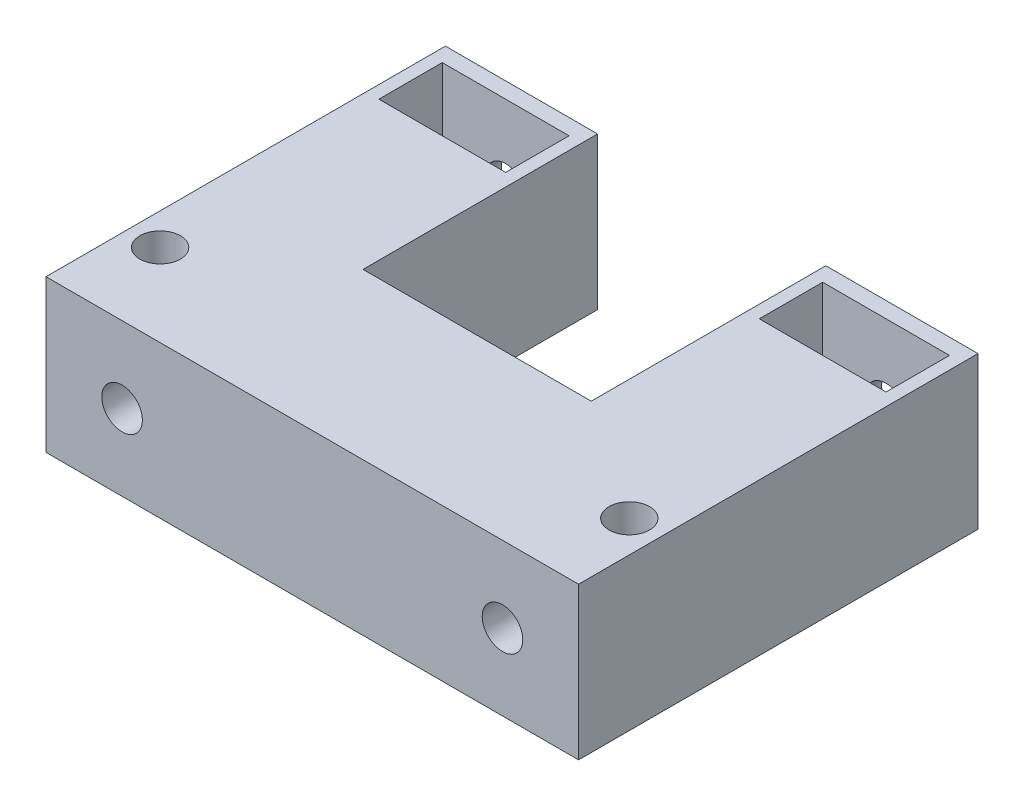
from build123d import *

# Parameters (mm, degrees)
SALIENTE_EXTRUIR1_DEPTH   = 5
SALIENTE_EXTRUIR1_2_DEPTH = 5
CROQUIS3_W                = 12
CROQUIS3_H                = 12
SALIENTE_EXTRUIR2_DEPTH   = 1.25
CROQUIS4_W                = 12
CROQUIS4_H                = 12
SALIENTE_EXTRUIR3_DEPTH   = 1.25
CROQUIS5_R                = 1.6
CORTAR_EXTRUIR1_DEPTH     = 1.25
CROQUIS9_R                = 1.6
CORTAR_EXTRUIR2_DEPTH     = 1.25
CROQUIS11_W               = 12
CROQUIS11_H               = 12
CROQUIS11_R               = 1.6
SALIENTE_EXTRUIR4_DEPTH   = 24
CROQUIS13_W               = 13
CROQUIS13_H               = 12
SALIENTE_EXTRUIR6_DEPTH   = 30
CROQUIS14_W               = 12
CROQUIS14_H               = 12
SALIENTE_EXTRUIR8_DEPTH   = 18.5
CROQUIS15_W               = 10
CROQUIS15_H               = 5
CORTAR_EXTRUIR3_DEPTH     = 12
CROQUIS16_R               = 1.6
CORTAR_EXTRUIR5_DEPTH     = 32
CROQUIS17_R               = 1.6
CORTAR_EXTRUIR6_DEPTH     = 12


with BuildPart() as part:
    # Croquis2 → Saliente-Extruir1 (new body)
    with BuildSketch(Plane.XY):
        Polygon((-5, -6), (-5, -5), (-5, 5), (-5, 6), (-6, 6), (-6, 5), (-6, -6), align=None)
    extrude(amount=SALIENTE_EXTRUIR1_DEPTH)



with BuildPart() as body_2:
    # Croquis2 → Saliente-Extruir1 2 (new body)
    with BuildSketch(Plane.XY):
        Polygon((5, 5), (5, -5), (5, -6), (6, -6), (6, 6), (5, 6), align=None)
    extrude(amount=SALIENTE_EXTRUIR1_2_DEPTH)


with BuildPart() as part_1:
    add(part.part)

    add(body_2.part)  # Saliente-Extruir2 merges body 2
    # Croquis3 → Saliente-Extruir2 (add)
    with BuildSketch(Plane(origin=(0, 0, 0), x_dir=(-1, 0, 0), z_dir=(0, 0, -1))):
        Rectangle(CROQUIS3_W, CROQUIS3_H)
    extrude(amount=SALIENTE_EXTRUIR2_DEPTH)

    # Croquis4 → Saliente-Extruir3 (add)
    with BuildSketch(Plane.XY.offset(5)):
        Rectangle(CROQUIS4_W, CROQUIS4_H)
    extrude(amount=SALIENTE_EXTRUIR3_DEPTH)

    # Croquis5 → Cortar-Extruir1 (cut)
    with BuildSketch(Plane.XY.offset(6.25)):
        Circle(CROQUIS5_R)
    extrude(amount=-CORTAR_EXTRUIR1_DEPTH, mode=Mode.SUBTRACT)

    # Croquis9 → Cortar-Extruir2 (cut)
    with BuildSketch(Plane.XY):
        Circle(CROQUIS9_R)
    extrude(amount=-CORTAR_EXTRUIR2_DEPTH, mode=Mode.SUBTRACT)

    # Croquis11 → Saliente-Extruir4 (add)
    with BuildSketch(Plane.XY.offset(6.25)):
        Rectangle(CROQUIS11_W, CROQUIS11_H)
        Circle(CROQUIS11_R, mode=Mode.SUBTRACT)
    extrude(amount=SALIENTE_EXTRUIR4_DEPTH)

    # Croquis13 → Saliente-Extruir6 (add)
    with BuildSketch(Plane(origin=(6, 0, 0), x_dir=(0, 0, -1), z_dir=(1, 0, 0))):
        with Locations((-23.75, 0)):
            Rectangle(CROQUIS13_W, CROQUIS13_H)
    extrude(amount=SALIENTE_EXTRUIR6_DEPTH)

    # Croquis14 → Saliente-Extruir8 (add)
    with BuildSketch(Plane(origin=(0, 0, 17.25), x_dir=(-1, 0, 0), z_dir=(0, 0, -1))):
        with Locations((-30, 0)):
            Rectangle(CROQUIS14_W, CROQUIS14_H)
    extrude(amount=SALIENTE_EXTRUIR8_DEPTH)

    # Croquis15 → Cortar-Extruir3 (cut)
    with BuildSketch(Plane(origin=(0, 6, 0), x_dir=(1, 0, 0), z_dir=(0, 1, 0))):
        with Locations((30, -2.5)):
            Rectangle(CROQUIS15_W, CROQUIS15_H)
    extrude(amount=-CORTAR_EXTRUIR3_DEPTH, mode=Mode.SUBTRACT)

    # Croquis16 → Cortar-Extruir5 (cut)
    with BuildSketch(Plane.XY.offset(30.25)):
        Circle(CROQUIS16_R)
        with Locations((30, 0)):
            Circle(CROQUIS16_R)
    extrude(amount=-CORTAR_EXTRUIR5_DEPTH, mode=Mode.SUBTRACT)

    # Croquis17 → Cortar-Extruir6 (cut)
    with BuildSketch(Plane(origin=(0, 6, 0), x_dir=(1, 0, 0), z_dir=(0, 1, 0))):
        with Locations((-3.5, -23.75)):
            Circle(CROQUIS17_R)
        with Locations((33.5, -23.75)):
            Circle(CROQUIS17_R)
    extrude(amount=-CORTAR_EXTRUIR6_DEPTH, mode=Mode.SUBTRACT)


solid = part_1.part
